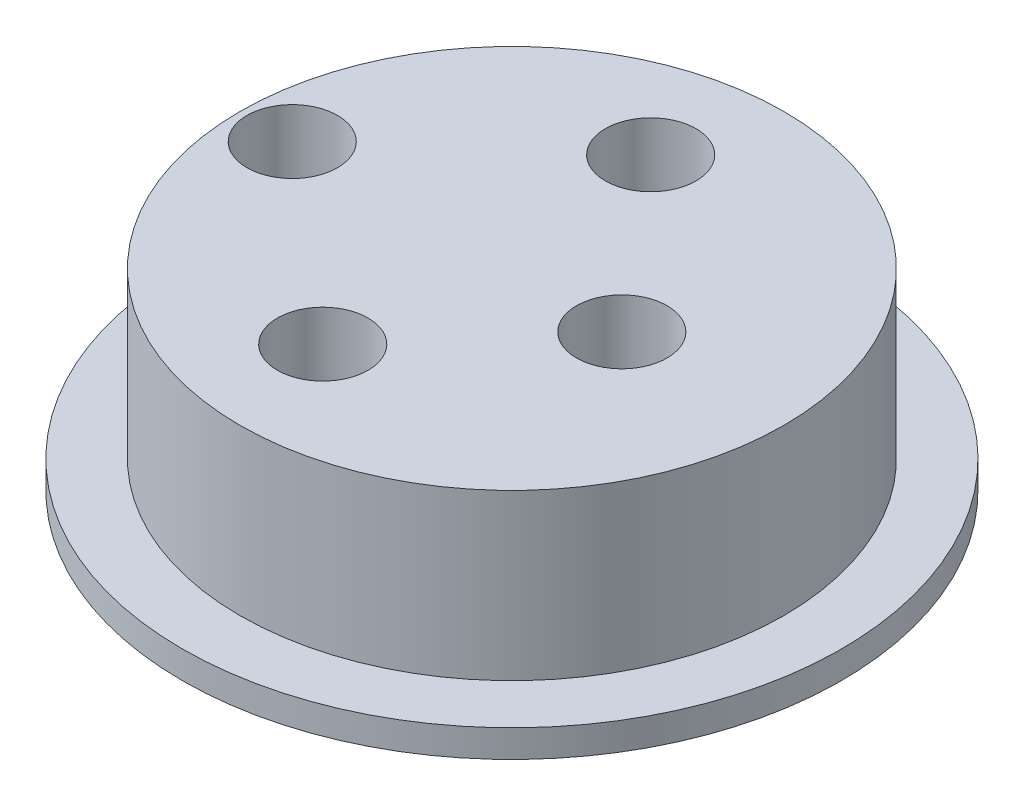
from build123d import *

# Parameters (mm, degrees)
SKETCH1_R           = 9.9
BOSS_EXTRUDE1_DEPTH = 7
SKETCH1_3_R         = 12
BOSS_EXTRUDE2_DEPTH = 1
SKETCH1_4_R         = 1.65
CUT_EXTRUDE1_DEPTH  = 31


with BuildPart() as part:
    # Sketch1 → Boss-Extrude1 (new body)
    with BuildSketch(Plane(origin=(0, 0, 0), x_dir=(1, 0, 0), z_dir=(0, 1, 0))):
        with Locations((1.975062748, 0.154777047)):
            Circle(SKETCH1_R)
    extrude(amount=BOSS_EXTRUDE1_DEPTH)

    # Sketch1_3 → Boss-Extrude2 (add)
    with BuildSketch(Plane(origin=(0, 0, 0), x_dir=(1, 0, 0), z_dir=(0, 1, 0))):
        with Locations((1.975062748, 0.154777047)):
            Circle(SKETCH1_3_R)
    extrude(amount=BOSS_EXTRUDE2_DEPTH)

    # Sketch1_4 → Cut-Extrude1 (cut)
    with BuildSketch(Plane(origin=(0, 0, 0), x_dir=(1, 0, 0), z_dir=(0, 1, 0))):
        with Locations((0.917956723, 6.264264553)):
            Circle(SKETCH1_4_R)
        with Locations((0.917956723, -5.677777134)):
            Circle(SKETCH1_4_R)
        with Locations((-6.024937252, 0.154777047)):
            Circle(SKETCH1_4_R)
        with Locations((5.975062748, 0.154777047)):
            Circle(SKETCH1_4_R)
    extrude(amount=CUT_EXTRUDE1_DEPTH, mode=Mode.SUBTRACT)


solid = part.part
